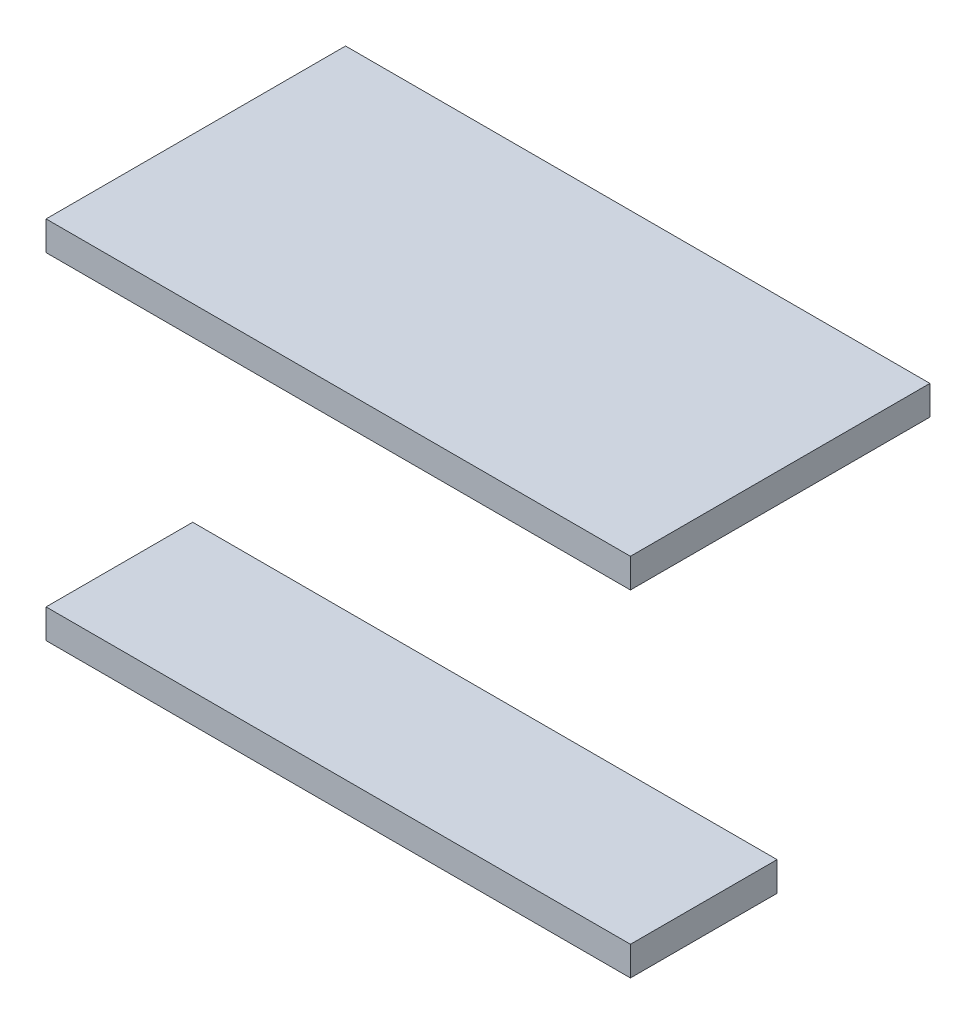
from build123d import *

# Parameters (mm, degrees)
SKETCH1_W             = 123
SKETCH1_H             = 12
BOSS_EXTRUDE1_DEPTH   = 240
SKETCH1_W_2           = 60.224174311
BOSS_EXTRUDE1_2_DEPTH = 240


with BuildPart() as part:
    # Sketch1 → Boss-Extrude1 (new body)
    with BuildSketch(Plane(origin=(0, 0, 0), x_dir=(0, 0, -1), z_dir=(1, 0, 0))):
        with Locations((73.5, -6)):
            Rectangle(SKETCH1_W, SKETCH1_H)
    extrude(amount=-BOSS_EXTRUDE1_DEPTH)


with BuildPart() as body_2:
    # Sketch1 → Boss-Extrude1 2 (new body)
    with BuildSketch(Plane(origin=(0, 0, 0), x_dir=(0, 0, -1), z_dir=(1, 0, 0))):
        with Locations((42.112087155, -144)):
            Rectangle(SKETCH1_W_2, SKETCH1_H)
    extrude(amount=-BOSS_EXTRUDE1_2_DEPTH)


solid = Compound([part.part, body_2.part])
